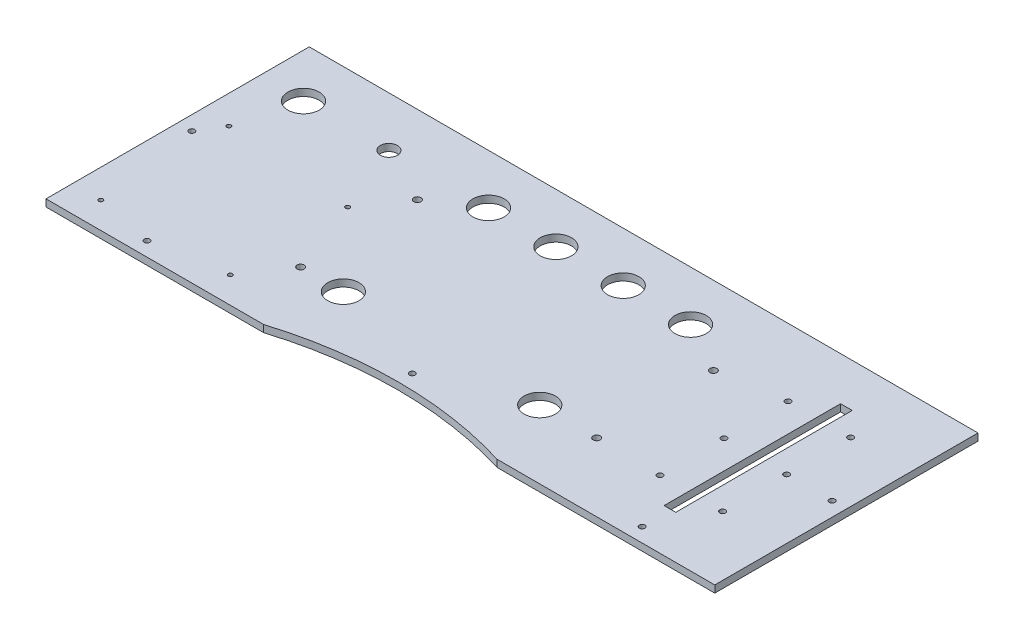
from build123d import *

# Parameters (mm, degrees)
SKETCH_1_R      = 2.5
SKETCH_1_R_2    = 11
SKETCH_1_R_3    = 2
SKETCH_1_R_4    = 1.5
SKETCH_1_R_5    = 6
SKETCH_1_W      = 8.2
SKETCH_1_H      = 124
EXTRUDE_1_DEPTH = 5


with BuildPart() as part:
    # 草图1 → 凸台-拉伸1 (new body)
    with BuildSketch(Plane(origin=(0, 0, 0), x_dir=(1, 0, 0), z_dir=(0, 1, 0))):
        with BuildLine():
            Line((-235, 92.5), (235, 92.5))
            Line((235, 92.5), (235, -92.5))
            Line((235, -92.5), (104, -92.5))
            Line((104, -92.5), (82, -92.5))
            ThreePointArc((82, -92.5), (0, -80.151224636), (-82, -92.5))
            Line((-82, -92.5), (-104, -92.5))
            Line((-104, -92.5), (-235, -92.5))
            Line((-235, -92.5), (-235, 92.5))
        make_face()
        with Locations((-104, 37.5)):
            Circle(SKETCH_1_R, mode=Mode.SUBTRACT)
        with Locations((-104, -44.5)):
            Circle(SKETCH_1_R, mode=Mode.SUBTRACT)
        with Locations((104, 37.5)):
            Circle(SKETCH_1_R, mode=Mode.SUBTRACT)
        with Locations((104, -44.5)):
            Circle(SKETCH_1_R, mode=Mode.SUBTRACT)
        with Locations((-74, 57.5)):
            Circle(SKETCH_1_R_2, mode=Mode.SUBTRACT)
        with Locations((-26.67, 57.5)):
            Circle(SKETCH_1_R_2, mode=Mode.SUBTRACT)
        with Locations((20.67, 57.5)):
            Circle(SKETCH_1_R_2, mode=Mode.SUBTRACT)
        with Locations((68, 57.5)):
            Circle(SKETCH_1_R_2, mode=Mode.SUBTRACT)
        with Locations((64, -44.5)):
            Circle(SKETCH_1_R_2, mode=Mode.SUBTRACT)
        with Locations((-204, 57.5)):
            Circle(SKETCH_1_R_2, mode=Mode.SUBTRACT)
        with Locations((-74, -44.5)):
            Circle(SKETCH_1_R_2, mode=Mode.SUBTRACT)
        with Locations((149, 0)):
            Circle(SKETCH_1_R_3, mode=Mode.SUBTRACT)
        with Locations((193, 0)):
            Circle(SKETCH_1_R_3, mode=Mode.SUBTRACT)
        with Locations((149, 45)):
            Circle(SKETCH_1_R_3, mode=Mode.SUBTRACT)
        with Locations((149, -45)):
            Circle(SKETCH_1_R_3, mode=Mode.SUBTRACT)
        with Locations((193, 45)):
            Circle(SKETCH_1_R_3, mode=Mode.SUBTRACT)
        with Locations((193, -45)):
            Circle(SKETCH_1_R_3, mode=Mode.SUBTRACT)
        with Locations((-124, -74)):
            Circle(SKETCH_1_R_4, mode=Mode.SUBTRACT)
        with Locations((-124, 8.5)):
            Circle(SKETCH_1_R_4, mode=Mode.SUBTRACT)
        with Locations((-215, -74)):
            Circle(SKETCH_1_R_4, mode=Mode.SUBTRACT)
        with Locations((-215, 16)):
            Circle(SKETCH_1_R_4, mode=Mode.SUBTRACT)
        with Locations((-144, 57.5)):
            Circle(SKETCH_1_R_5, mode=Mode.SUBTRACT)
        with Locations((0, -70.101989155)):
            Circle(SKETCH_1_R_3, mode=Mode.SUBTRACT)
        with Locations((-174, -82.5)):
            Circle(SKETCH_1_R_3, mode=Mode.SUBTRACT)
        with Locations((174, -82.5)):
            Circle(SKETCH_1_R_3, mode=Mode.SUBTRACT)
        with Locations((-225, 0)):
            Circle(SKETCH_1_R_3, mode=Mode.SUBTRACT)
        with Locations((225, 0)):
            Circle(SKETCH_1_R_3, mode=Mode.SUBTRACT)
        with Locations((173, 0)):
            Rectangle(SKETCH_1_W, SKETCH_1_H, mode=Mode.SUBTRACT)
    extrude(amount=EXTRUDE_1_DEPTH)


solid = part.part
